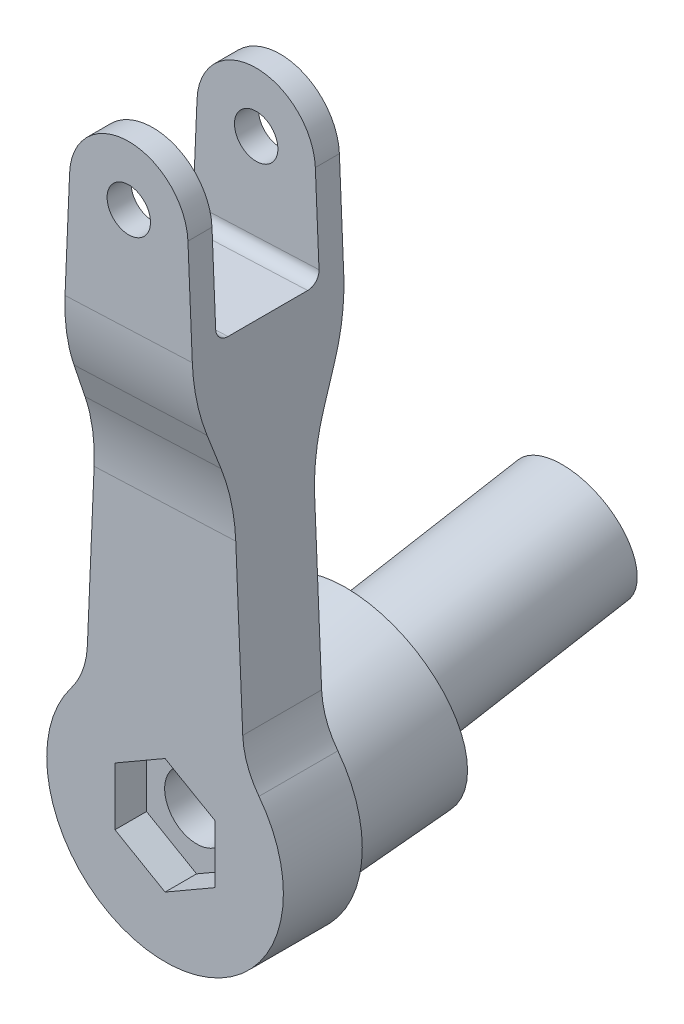
from build123d import *

# Parameters (mm, degrees)
SKETCH1_R               = 2.75
BOSS_EXTRUDE1_DEPTH     = 19.2
SKETCH13_OUTSIDE_W      = 41
SKETCH13_OUTSIDE_H      = 115.36
CUT_EXTRUDE4_DEPTH      = 84.275329734
CUT_EXTRUDE4_DEPTH_BACK = 84.275329734
CUT_EXTRUDE2_DEPTH      = 4
SKETCH4_R               = 4.05
CUT_EXTRUDE3_DEPTH      = 20
FILLET4_R               = 10
BOSS_EXTRUDE2_REACH     = 83.7
SKETCH9_R               = 13
SKETCH10_R              = 8
BOSS_EXTRUDE3_DEPTH     = 27
DRAFT1_ANGLE            = -3
FILLET5_R               = 25
SKETCH14_R              = 2
CUT_EXTRUDE5_DEPTH      = 4
FILLET6_R               = 1.5


with BuildPart() as part:
    # Sketch1 → Boss-Extrude1 (new body)
    with BuildSketch(Plane.XY):
        with BuildLine():
            Line((-7.5, 70.183778092), (-10, 11.180339887))
            ThreePointArc((-10, 11.180339887), (0, -15), (10, 11.180339887))
            Line((10, 11.180339887), (7.5, 70.183778092))
            ThreePointArc((7.5, 70.183778092), (0, 77.372729176), (-7.5, 70.183778092))
        make_face()
        with Locations((0, 69.866)):
            Circle(SKETCH1_R, mode=Mode.SUBTRACT)
    extrude(amount=BOSS_EXTRUDE1_DEPTH)

    # Sketch13 outside → Cut-Extrude4 (cut, two sides)
    with BuildSketch(Plane(origin=(10.454946348, 0.442980387, 0), x_dir=(0, 0, -1), z_dir=(0.9991035808766652, 0.042332430587259585, 0))) as cut_extrude4_sk:
        with Locations((-9.6, 31.158)):
            Rectangle(SKETCH13_OUTSIDE_W, SKETCH13_OUTSIDE_H)
        Polygon((-16.15, 77.310099957), (-16.15, 57.310099957), (-3.05, 57.310099957), (-3.05, 77.310099957), (0, 77.310099957), (0, 52.310099957), (-4.6, 39.671703828), (-4.6, -15), (-14.6, -15), (-14.6, 39.671703828), (-19.2, 52.310099957), (-19.2, 77.310099957), align=None, mode=Mode.SUBTRACT)
    extrude(amount=CUT_EXTRUDE4_DEPTH, mode=Mode.SUBTRACT)
    extrude(cut_extrude4_sk.sketch, amount=-CUT_EXTRUDE4_DEPTH_BACK, mode=Mode.SUBTRACT)

    # Sketch3 → Cut-Extrude2 (cut)
    with BuildSketch(Plane.XY.offset(14.6)):
        Polygon((0, 7.332348419), (-6.35, 3.666174209), (-6.35, -3.666174209), (0, -7.332348419), (6.35, -3.666174209), (6.35, 3.666174209), align=None)
    extrude(amount=-CUT_EXTRUDE2_DEPTH, mode=Mode.SUBTRACT)

    # Sketch4 → Cut-Extrude3 (cut)
    with BuildSketch(Plane.XY.offset(10.6)):
        Circle(SKETCH4_R)
    extrude(amount=-CUT_EXTRUDE3_DEPTH, mode=Mode.SUBTRACT)

    # Fillet4
    fillet4_edges = [part.edges().sort_by_distance(p)[0] for p in [
        (10, 11.180339887, 9.6),
        (-10, 11.180339887, 9.6),
    ]]
    fillet(fillet4_edges, radius=FILLET4_R)

    # Boss-Extrude2: up to this plane
    boss_extrude2_end = Plane(origin=(-17.286936373, 38.974843589, 4.6), z_dir=(0, 0, -1))
    # Sketch9 → Boss-Extrude2 (add, up to the surface)
    with BuildSketch(Plane(origin=(0, 2.715435503, -10.4), x_dir=(-1, 0, 0), z_dir=(0, 0.17364817766692367, -0.9848077530122092)), mode=Mode.PRIVATE) as boss_extrude2_sk1:
        with Locations(Location((0, -0.868240888, 0), (0, 0, 90))):
            Circle(SKETCH9_R)
    boss_extrude2_tool1 = split(extrude(boss_extrude2_sk1.sketch, amount=-BOSS_EXTRUDE2_REACH, mode=Mode.PRIVATE), bisect_by=boss_extrude2_end, keep=Keep.BOTH, mode=Mode.PRIVATE)
    add(boss_extrude2_tool1.solids().sort_by_distance((0, 1.860385, -10.550768))[0])

    # Sketch10 → Boss-Extrude3 (add)
    with BuildSketch(Plane(origin=(0, 1.860385145, -10.550768448), x_dir=(-1, 0, 0), z_dir=(0, 0.17364817766692367, -0.9848077530122092))):
        with Locations(Location((0, 0, 0), (0, 0, 90))):
            Circle(SKETCH10_R)
    extrude(amount=BOSS_EXTRUDE3_DEPTH)

    # Draft1
    draft1_faces = [part.faces().sort_by_distance(p)[0] for p in [
        (0, -12.485127219, -4.05734127),
    ]]
    draft(draft1_faces, Plane(origin=(0, 1.860385145, -10.550768448), x_dir=(0, -0.9848077530122092, -0.17364817766692367), z_dir=(0, 0.17364817766692367, -0.9848077530122092)), DRAFT1_ANGLE)

    # Fillet5
    fillet5_edges = [part.edges().sort_by_distance(p)[0] for p in [
        (-0.01578265, 39.706629492, 4.6),
        (-0.01578265, 39.706629492, 14.6),
        (-0.014820438, 52.356405855, 19.2),
        (-0.014820438, 52.356405855, 0),
    ]]
    fillet(fillet5_edges, radius=FILLET5_R)

    # Sketch14 → Cut-Extrude5 (cut)
    with BuildSketch(Plane(origin=(0, 6.548885942, -37.140577779), x_dir=(-1, 0, 0), z_dir=(0, 0.17364817766692367, -0.9848077530122092))):
        with Locations(Location((-3.464101615, 2, 0), (0, 0, 90))):
            Circle(SKETCH14_R)
        with Locations(Location((3.464101615, 2, 0), (0, 0, 90))):
            Circle(SKETCH14_R)
        with Locations(Location((0, -4, 0), (0, 0, 90))):
            Circle(SKETCH14_R)
    extrude(amount=-CUT_EXTRUDE5_DEPTH, mode=Mode.SUBTRACT)

    # Fillet6
    fillet6_edges = [part.edges().sort_by_distance(p)[0] for p in [
        (-9.82e-07, -13.079573194, 4.6),
        (-0.014439768, 57.360908102, 3.05),
        (-0.014439768, 57.360908102, 16.15),
    ]]
    fillet(fillet6_edges, radius=FILLET6_R)


solid = part.part
